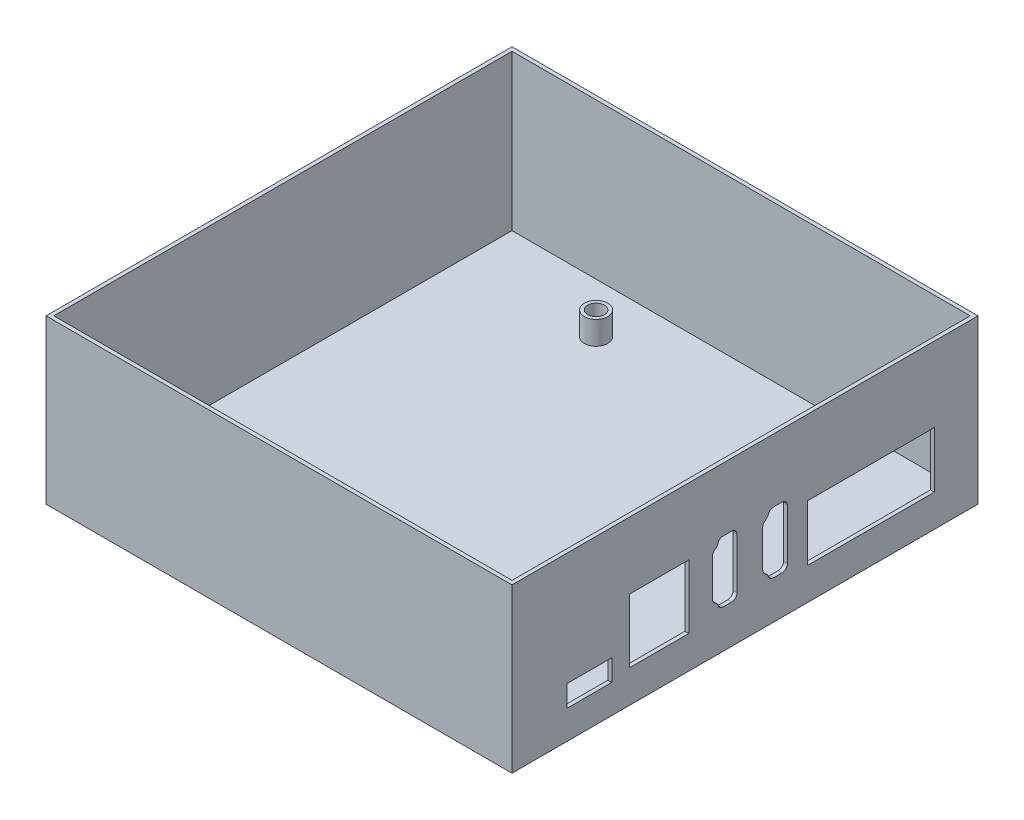
from build123d import *

# Parameters (mm, degrees)
SKETCH1_W           = 120
SKETCH1_H           = 120
BOSS_EXTRUDE1_DEPTH = 2
SKETCH3_R           = 3
SKETCH3_R_2         = 2.15
BOSS_EXTRUDE2_DEPTH = 6
SKETCH4_W           = 120
SKETCH4_H           = 120
SKETCH4_W_2         = 118
SKETCH4_H_2         = 118
BOSS_EXTRUDE3_DEPTH = 40
SKETCH5_W           = 15.299999553
SKETCH5_H           = 16.42
SKETCH5_W_2         = 32.63620328
SKETCH5_H_2         = 14.399997005
SKETCH5_W_3         = 11.5
SKETCH5_H_3         = 5.5
CUT_EXTRUDE1_DEPTH  = 1


with BuildPart() as part:
    # Sketch1 → Boss-Extrude1 (new body)
    with BuildSketch(Plane(origin=(0, 0, 0), x_dir=(1, 0, 0), z_dir=(0, 1, 0))):
        Rectangle(SKETCH1_W, SKETCH1_H)
    extrude(amount=BOSS_EXTRUDE1_DEPTH)

    # Sketch3 → Boss-Extrude2 (add)
    with BuildSketch(Plane(origin=(0, 2, 0), x_dir=(1, 0, 0), z_dir=(0, 1, 0))):
        with Locations((-24.500233826, 46.14332907)):
            Circle(SKETCH3_R)
        with Locations((-24.500233826, 46.14332907)):
            Circle(SKETCH3_R_2, mode=Mode.SUBTRACT)
        with Locations((33.499766618, 46.136550123)):
            Circle(SKETCH3_R)
        with Locations((33.499766618, 46.136550123)):
            Circle(SKETCH3_R_2, mode=Mode.SUBTRACT)
        with Locations((33.801832122, -42.455500627)):
            Circle(SKETCH3_R)
        with Locations((33.801832122, -42.455500627)):
            Circle(SKETCH3_R_2, mode=Mode.SUBTRACT)
        with Locations((-24.541068319, -42.448681603)):
            Circle(SKETCH3_R)
        with Locations((-24.541068319, -42.448681603)):
            Circle(SKETCH3_R_2, mode=Mode.SUBTRACT)
    extrude(amount=BOSS_EXTRUDE2_DEPTH)

    # Sketch4 → Boss-Extrude3 (add)
    with BuildSketch(Plane(origin=(0, 2, 0), x_dir=(1, 0, 0), z_dir=(0, 1, 0))):
        Rectangle(SKETCH4_W, SKETCH4_H)
        Rectangle(SKETCH4_W_2, SKETCH4_H_2, mode=Mode.SUBTRACT)
    extrude(amount=BOSS_EXTRUDE3_DEPTH)

    # Sketch5 → Cut-Extrude1 (cut)
    with BuildSketch(Plane(origin=(60, 0, 0), x_dir=(0, 0, -1), z_dir=(1, 0, 0))):
        with Locations((-22.123446946, 16.599997028)):
            Rectangle(SKETCH5_W, SKETCH5_H)
        with BuildLine():
            Line((-6.960880715, 24.719998619), (-7.078005207, 24.349104393))
            Line((-7.078005207, 24.349104393), (-7.938323111, 23.560479642))
            add(Edge.make_bspline(
                [(-7.938323111, 23.560479642), (-8.008708428, 23.495959767), (-8.135677464, 23.353602564), (-8.283483399, 23.096453844), (-8.373165531, 22.813736363), (-8.392308628, 22.623946344), (-8.392308628, 22.528463847)],
                knots=[0, 0, 0, 0, 0.25, 0.5, 0.75, 1, 1, 1, 1], degree=3))
            Line((-8.392308628, 22.528463847), (-8.392308628, 13.068365563))
            add(Edge.make_bspline(
                [(-8.392308628, 13.068365563), (-8.392308628, 12.972883067), (-8.373165531, 12.783093048), (-8.283483399, 12.500375567), (-8.135677464, 12.243226847), (-8.008708428, 12.100869643), (-7.938323111, 12.036349768)],
                knots=[0, 0, 0, 0, 0.25, 0.5, 0.75, 1, 1, 1, 1], degree=3))
            Line((-7.938323111, 12.036349768), (-7.078005207, 11.247725017))
            Line((-7.078005207, 11.247725017), (-6.960880715, 10.876830791))
            add(Edge.make_bspline(
                [(-6.960880715, 10.876830791), (-6.917752001, 10.740256529), (-6.792916696, 10.483611985), (-6.46908795, 10.147865428), (-6.051410861, 9.940171767), (-5.769087247, 9.898414705), (-5.625864989, 9.898414705)],
                knots=[0, 0, 0, 0, 0.25, 0.5, 0.75, 1, 1, 1, 1], degree=3))
            Line((-5.625864989, 9.898414705), (-3.442308658, 9.898414705))
            add(Edge.make_bspline(
                [(-3.442308658, 9.898414705), (-3.267434145, 9.898414705), (-2.925471239, 9.958566446), (-2.42155584, 10.277661886), (-2.102460404, 10.781577287), (-2.042308664, 11.123540192), (-2.042308664, 11.298414705)],
                knots=[0, 0, 0, 0, 0.25, 0.5, 0.75, 1, 1, 1, 1], degree=3))
            Line((-2.042308664, 11.298414705), (-2.042308664, 24.298414705))
            add(Edge.make_bspline(
                [(-2.042308664, 24.298414705), (-2.042308664, 24.473289219), (-2.102460404, 24.815252124), (-2.42155584, 25.319167525), (-2.925471239, 25.638262964), (-3.267434145, 25.698414705), (-3.442308658, 25.698414705)],
                knots=[0, 0, 0, 0, 0.25, 0.5, 0.75, 1, 1, 1, 1], degree=3))
            Line((-3.442308658, 25.698414705), (-5.625864989, 25.698414705))
            add(Edge.make_bspline(
                [(-5.625864989, 25.698414705), (-5.769087247, 25.698414705), (-6.051410861, 25.656657644), (-6.46908795, 25.448963983), (-6.792916696, 25.113217425), (-6.917752001, 24.856572882), (-6.960880715, 24.719998619)],
                knots=[0, 0, 0, 0, 0.25, 0.5, 0.75, 1, 1, 1, 1], degree=3))
        make_face()
        with BuildLine():
            Line((5.997249079, 24.719998619), (5.880124588, 24.349104393))
            Line((5.880124588, 24.349104393), (5.019806683, 23.560479642))
            add(Edge.make_bspline(
                [(5.019806683, 23.560479642), (4.949421366, 23.495959767), (4.82245233, 23.353602564), (4.674646395, 23.096453844), (4.584964263, 22.813736363), (4.565821167, 22.623946344), (4.565821167, 22.528463847)],
                knots=[0, 0, 0, 0, 0.25, 0.5, 0.75, 1, 1, 1, 1], degree=3))
            Line((4.565821167, 22.528463847), (4.565821167, 13.068365563))
            add(Edge.make_bspline(
                [(4.565821167, 13.068365563), (4.565821167, 12.972883067), (4.584964263, 12.783093048), (4.674646395, 12.500375567), (4.82245233, 12.243226847), (4.949421366, 12.100869643), (5.019806683, 12.036349768)],
                knots=[0, 0, 0, 0, 0.25, 0.5, 0.75, 1, 1, 1, 1], degree=3))
            Line((5.019806683, 12.036349768), (5.880124588, 11.247725017))
            Line((5.880124588, 11.247725017), (5.997249079, 10.876830791))
            add(Edge.make_bspline(
                [(5.997249079, 10.876830791), (6.040377794, 10.740256529), (6.165213099, 10.483611985), (6.489041844, 10.147865428), (6.906718933, 9.940171767), (7.189042547, 9.898414705), (7.332264805, 9.898414705)],
                knots=[0, 0, 0, 0, 0.25, 0.5, 0.75, 1, 1, 1, 1], degree=3))
            Line((7.332264805, 9.898414705), (9.515821136, 9.898414705))
            add(Edge.make_bspline(
                [(9.515821136, 9.898414705), (9.69069565, 9.898414705), (10.032658555, 9.958566446), (10.536573954, 10.277661886), (10.85566939, 10.781577287), (10.91582113, 11.123540192), (10.91582113, 11.298414705)],
                knots=[0, 0, 0, 0, 0.25, 0.5, 0.75, 1, 1, 1, 1], degree=3))
            Line((10.91582113, 11.298414705), (10.91582113, 24.298414705))
            add(Edge.make_bspline(
                [(10.91582113, 24.298414705), (10.91582113, 24.473289219), (10.85566939, 24.815252124), (10.536573954, 25.319167525), (10.032658555, 25.638262964), (9.69069565, 25.698414705), (9.515821136, 25.698414705)],
                knots=[0, 0, 0, 0, 0.25, 0.5, 0.75, 1, 1, 1, 1], degree=3))
            Line((9.515821136, 25.698414705), (7.332264805, 25.698414705))
            add(Edge.make_bspline(
                [(7.332264805, 25.698414705), (7.189042547, 25.698414705), (6.906718933, 25.656657644), (6.489041844, 25.448963983), (6.165213099, 25.113217425), (6.040377793, 24.856572882), (5.997249079, 24.719998619)],
                knots=[0, 0, 0, 0, 0.25, 0.5, 0.75, 1, 1, 1, 1], degree=3))
        make_face()
        with Locations((32.443720838, 15.498417022)):
            Rectangle(SKETCH5_W_2, SKETCH5_H_2)
        with Locations((-40.056026235, 10.14841852)):
            Rectangle(SKETCH5_W_3, SKETCH5_H_3)
    extrude(amount=-CUT_EXTRUDE1_DEPTH, mode=Mode.SUBTRACT)


solid = part.part
